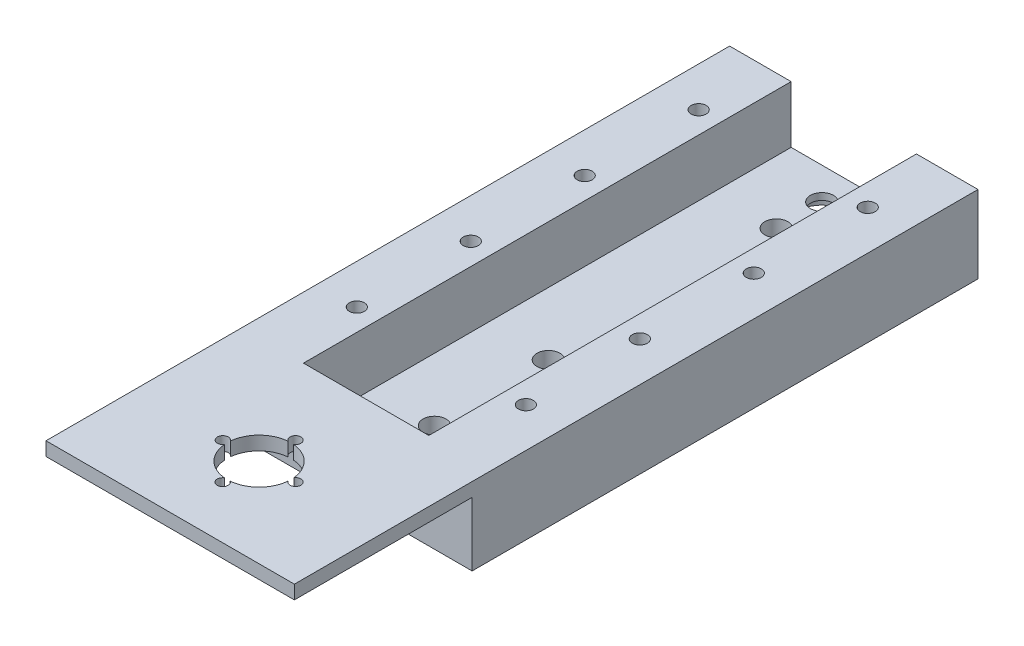
from build123d import *

# Parameters (mm, degrees)
SKETCH1_W                  = 54.5
SKETCH1_H                  = 111
BOSS_EXTRUDE1_DEPTH        = 4.5
SKETCH2_W                  = 13.5
SKETCH2_H                  = 111
BOSS_EXTRUDE2_DEPTH        = 12.5
M4X0_7_TAPPED_HOLE1_D      = 3.3
SKETCH6_W                  = 4
SKETCH6_H                  = 12.5
BOSS_EXTRUDE3_DEPTH        = 37
SKETCH7_W                  = 54.5
SKETCH7_H                  = 3
BOSS_EXTRUDE5_DEPTH        = 39
SKETCH8_R                  = 7
CUT_EXTRUDE1_DEPTH         = 3
M2_CLEARANCE_HOLE1_D       = 2.4
F_8_0_199_DIAMETER_HOLE1_D = 5.0546
SKETCH12_R                 = 5.5
CUT_EXTRUDE3_DEPTH         = 3


with BuildPart() as part:
    # Sketch1 → Boss-Extrude1 (new body)
    with BuildSketch(Plane(origin=(0, 0, 0), x_dir=(1, 0, 0), z_dir=(0, 1, 0))):
        with Locations((-13.399543841, 44.129312584)):
            Rectangle(SKETCH1_W, SKETCH1_H)
    extrude(amount=BOSS_EXTRUDE1_DEPTH)

    # Sketch2 → Boss-Extrude2 (add)
    with BuildSketch(Plane(origin=(0, 4.5, 0), x_dir=(1, 0, 0), z_dir=(0, 1, 0))):
        with Locations((7.100456159, 44.129312584)):
            Rectangle(SKETCH2_W, SKETCH2_H)
        with Locations((-33.899543841, 44.129312584)):
            Rectangle(SKETCH2_W, SKETCH2_H)
    extrude(amount=BOSS_EXTRUDE2_DEPTH)

    # M4x0.7 Tapped Hole1 (through all)
    with Locations(Plane(origin=(-31.949543841, 17, -9.129312584), x_dir=(0, 0, 1), z_dir=(0, 1, 0))):
        with Locations((0, 0), (-25, 0), (-50, 0), (-75, 0), (0, 37.1), (-25, 37.1), (-50, 37.1), (-75, 37.1)):
            Hole(M4X0_7_TAPPED_HOLE1_D / 2)

    # Sketch6 → Boss-Extrude3 (add)
    with BuildSketch(Plane(origin=(-27.149543841, 0, 0), x_dir=(0, 0, -1), z_dir=(1, 0, 0))):
        with Locations((-9.370687416, 10.75)):
            Rectangle(SKETCH6_W, SKETCH6_H)
    extrude(amount=BOSS_EXTRUDE3_DEPTH)

    # Sketch7 → Boss-Extrude5 (add)
    with BuildSketch(Plane.XY.offset(11.370687416)):
        with Locations((-13.399543841, 15.5)):
            Rectangle(SKETCH7_W, SKETCH7_H)
    extrude(amount=BOSS_EXTRUDE5_DEPTH)

    # Sketch8 → Cut-Extrude1 (cut)
    with BuildSketch(Plane(origin=(0, 17, 0), x_dir=(1, 0, 0), z_dir=(0, 1, 0))):
        with Locations((-13.399543841, -30.870687416)):
            Circle(SKETCH8_R)
    extrude(amount=-CUT_EXTRUDE1_DEPTH, mode=Mode.SUBTRACT)

    # M2 Clearance Hole1 (through all)
    with Locations(Plane(origin=(-21.371437118, 17, 30.847906254), x_dir=(0, 0, 1), z_dir=(0, 1, 0))):
        with Locations((0, 0), (-7.977218838, 7.971893277), (8.022781162, 7.971893277), (-0.002806072, 15.940961576)):
            Hole(M2_CLEARANCE_HOLE1_D / 2)

    # #8 (0.199) Diameter Hole1 (through all)
    with Locations(Plane(origin=(-13.399543841, 4.5, 2.370687416), x_dir=(0, 0, 1), z_dir=(0, 1, 0))):
        with Locations((0, 0), (-10, 0), (-35, 0), (-85, 0), (-95, 0)):
            Hole(F_8_0_199_DIAMETER_HOLE1_D / 2)

    # Sketch12 → Cut-Extrude3 (cut)
    with BuildSketch(Plane(origin=(0, 0, 0), x_dir=(-1, 0, 0), z_dir=(0, -1, 0))):
        with Locations((13.399543841, 92.629312584)):
            Circle(SKETCH12_R)
    extrude(amount=-CUT_EXTRUDE3_DEPTH, mode=Mode.SUBTRACT)


solid = part.part
